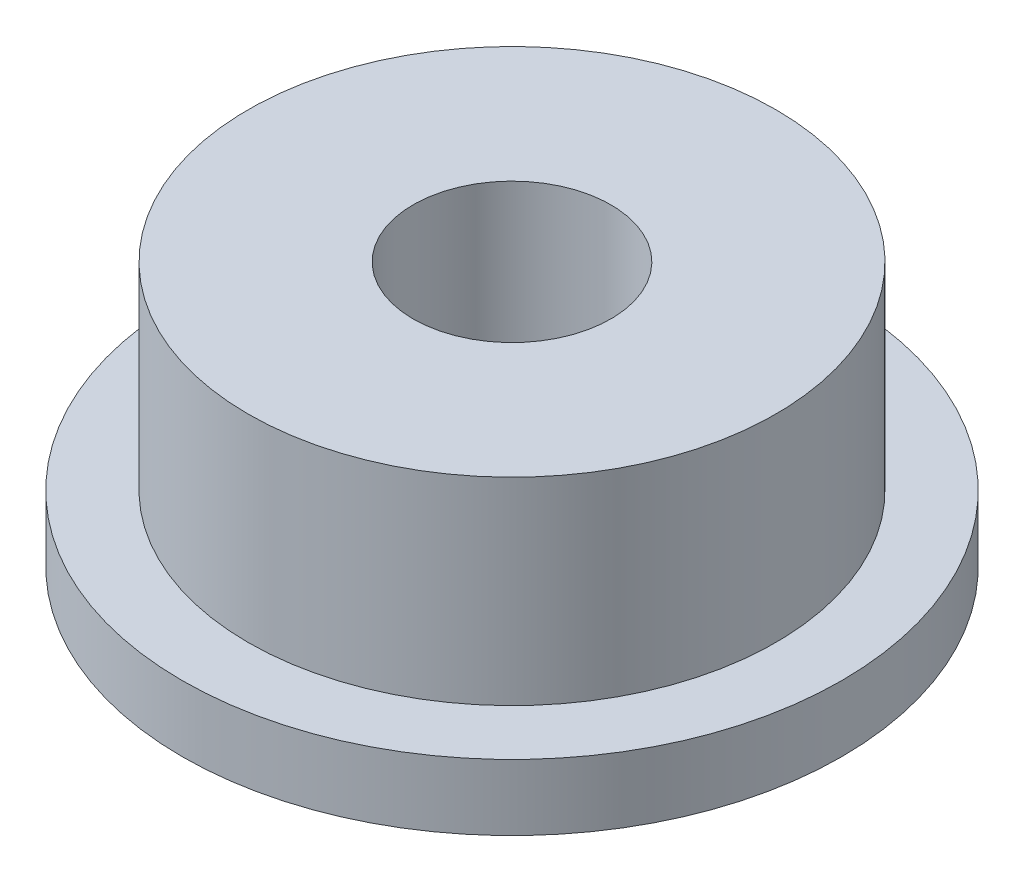
from build123d import *


with BuildPart() as part:
    # 草图1 → 旋转1 (revolve)
    with BuildSketch(Plane.XY):
        Polygon((1.5, -4), (1.5, 0), (4, 0), (4, -3), (5, -3), (5, -4), align=None)
    revolve(axis=Axis((0, 0, 0), (0, -1, 0)))


solid = part.part
